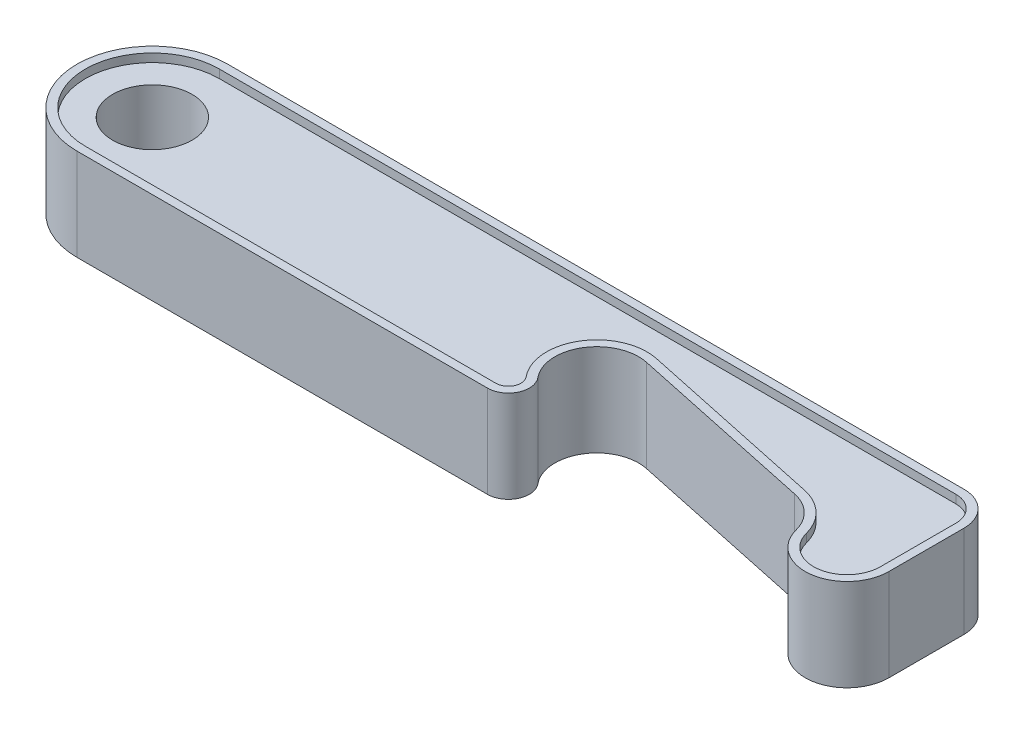
from build123d import *

# Parameters (mm, degrees)
SKETCH6_R           = 4.75
BOSS_EXTRUDE1_DEPTH = 4.5
BOSS_EXTRUDE2_DEPTH = 5.5


with BuildPart() as part:
    # Sketch6 → Boss-Extrude1 (new, symmetric)
    with BuildSketch(Plane(origin=(0, 0, 0), x_dir=(1, 0, 0), z_dir=(0, 1, 0))):
        with BuildLine():
            Line((88, 8), (0, 8))
            ThreePointArc((0, 8), (-8, 0), (0, -8))
            Line((0, -8), (49.040217235, -8))
            ThreePointArc((49.040217235, -8), (50.397559636, -7.138452508), (50.195682115, -5.543495472))
            ThreePointArc((50.195682115, -5.543495472), (49.68486052, 1.389866291), (56.065011779, 4.151408242))
            Line((56.065011779, 4.151408242), (78.565011779, -0.631114396))
            ThreePointArc((78.565011779, -0.631114396), (81.467470443, -2.166630539), (83.127016654, -5))
            ThreePointArc((83.127016654, -5), (87.50401717, -7.968118785), (91, -4))
            Line((91, -4), (91, 5))
            ThreePointArc((91, 5), (90.121320344, 7.121320344), (88, 8))
        make_face()
        Circle(SKETCH6_R, mode=Mode.SUBTRACT)
    extrude(amount=BOSS_EXTRUDE1_DEPTH, both=True)

    # Sketch6_3 → Boss-Extrude2 (add, symmetric)
    with BuildSketch(Plane(origin=(0, 0, 0), x_dir=(1, 0, 0), z_dir=(0, 1, 0))):
        with BuildLine():
            Line((88, 9), (0, 9))
            ThreePointArc((0, 9), (-9, 0), (0, -9))
            Line((0, -9), (49.040217235, -9))
            ThreePointArc((49.040217235, -9), (51.302454571, -7.564087513), (50.965992035, -4.905825787))
            ThreePointArc((50.965992035, -4.905825787), (50.540307373, 0.871975682), (55.857100089, 3.173260641))
            Line((55.857100089, 3.173260641), (78.357100089, -1.609261996))
            ThreePointArc((78.357100089, -1.609261996), (80.775815642, -2.888858783), (82.158770817, -5.25))
            ThreePointArc((82.158770817, -5.25), (87.630021462, -8.960148481), (92, -4))
            Line((92, -4), (92, 5))
            ThreePointArc((92, 5), (90.828427125, 7.828427125), (88, 9))
        make_face()
        with BuildLine():
            ThreePointArc((0, -8), (-8, 0), (0, 8))
            Line((0, 8), (88, 8))
            ThreePointArc((88, 8), (90.121320344, 7.121320344), (91, 5))
            Line((91, 5), (91, -4))
            ThreePointArc((91, -4), (87.50401717, -7.968118785), (83.127016654, -5))
            ThreePointArc((83.127016654, -5), (81.467470443, -2.166630539), (78.565011779, -0.631114396))
            Line((78.565011779, -0.631114396), (56.065011779, 4.151408242))
            ThreePointArc((56.065011779, 4.151408242), (49.68486052, 1.389866291), (50.195682115, -5.543495472))
            ThreePointArc((50.195682115, -5.543495472), (50.397559636, -7.138452508), (49.040217235, -8))
            Line((49.040217235, -8), (0, -8))
        make_face(mode=Mode.SUBTRACT)
    extrude(amount=BOSS_EXTRUDE2_DEPTH, both=True)


solid = part.part
